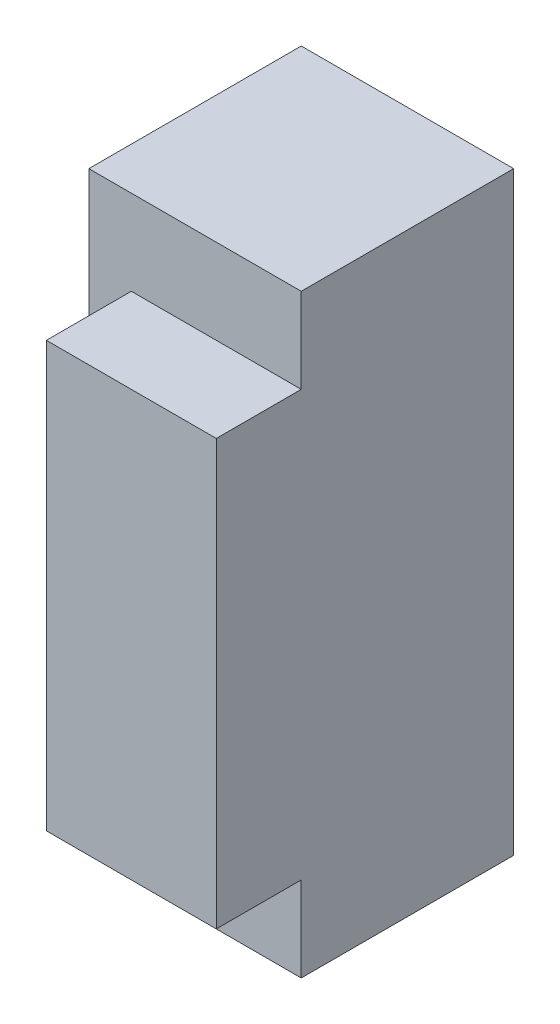
from build123d import *

# Parameters (mm, degrees)
SKETCH1_W      = 5
SKETCH1_H      = 14
EXTRUDE1_DEPTH = 5
SKETCH2_W      = 4
SKETCH2_H      = 10
EXTRUDE2_DEPTH = 2


with BuildPart() as part:
    # Sketch1 → Extrude1 (new body)
    with BuildSketch(Plane.XY):
        Rectangle(SKETCH1_W, SKETCH1_H)
    extrude(amount=EXTRUDE1_DEPTH)

    # Sketch2 → Extrude2 (add)
    with BuildSketch(Plane.XY.offset(5)):
        with Locations((0.5, 0)):
            Rectangle(SKETCH2_W, SKETCH2_H)
    extrude(amount=EXTRUDE2_DEPTH)


solid = part.part
